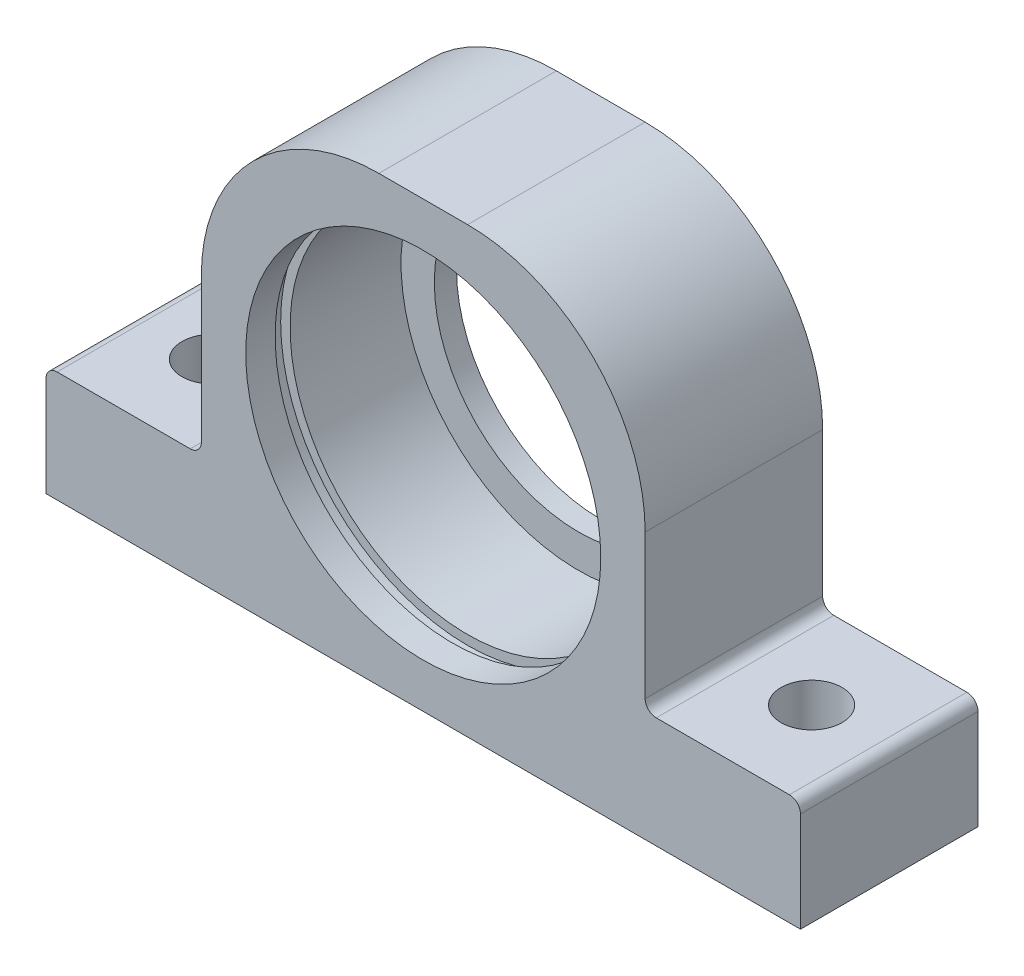
from build123d import *

# Parameters (mm, degrees)
EXTRUDE_1_DEPTH      = 8
EXTRUDE_1_DEPTH_BACK = 8
SKETCH_3_W           = 2.75
SKETCH_3_H           = 10
SKETCH_4_W           = 2.75
SKETCH_4_H           = 10


with BuildPart() as part:
    # ｽｹｯﾁ1 → ﾎﾞｽ - 押し出し1 (new, two sides: drawn at the far end of the back side and taken through both)
    with BuildSketch(Plane.XY.offset(-EXTRUDE_1_DEPTH_BACK)):
        with BuildLine():
            Line((-34, 9), (-34, 0))
            Line((-34, 0), (34, 0))
            Line((34, 0), (34, 9))
            ThreePointArc((34, 9), (33.707106781, 9.707106781), (33, 10))
            Line((33, 10), (21, 10))
            ThreePointArc((21, 10), (20.292893219, 10.292893219), (20, 11))
            Line((20, 11), (20, 24))
            ThreePointArc((20, 24), (15.313708499, 35.313708499), (4, 40))
            Line((4, 40), (-4, 40))
            ThreePointArc((-4, 40), (-15.313708499, 35.313708499), (-20, 24))
            Line((-20, 24), (-20, 11))
            ThreePointArc((-20, 11), (-20.292893219, 10.292893219), (-21, 10))
            Line((-21, 10), (-33, 10))
            ThreePointArc((-33, 10), (-33.707106781, 9.707106781), (-34, 9))
        make_face()
    extrude(amount=EXTRUDE_1_DEPTH + EXTRUDE_1_DEPTH_BACK)

    # ｽｹｯﾁ2 → ｶｯﾄ - 回転1 (revolve, cut)
    with BuildSketch(Plane(origin=(0, 0, 0), x_dir=(0, 0, -1), z_dir=(1, 0, 0))):
        Polygon((-8, 20), (-8, 36), (-5.35, 36), (-5.35, 36.85), (-4, 36.85), (-4, 36), (6, 36), (6, 33), (8, 33), (8, 20), align=None)
    revolve(axis=Axis((0, 20, -8), (0, 0, 1)), mode=Mode.SUBTRACT)

    # ｽｹｯﾁ3 → ｶｯﾄ - 回転2 (revolve, cut)
    with BuildSketch(Plane.XY):
        with Locations((28.375, 5)):
            Rectangle(SKETCH_3_W, SKETCH_3_H)
    revolve(axis=Axis((27, 0, 0), (0, 1, 0)), mode=Mode.SUBTRACT)

    # ｽｹｯﾁ4 → ｶｯﾄ - 回転3 (revolve, cut)
    with BuildSketch(Plane.XY):
        with Locations((-25.625, 5)):
            Rectangle(SKETCH_4_W, SKETCH_4_H)
    revolve(axis=Axis((-27, 0, 0), (0, 1, 0)), mode=Mode.SUBTRACT)


solid = part.part
